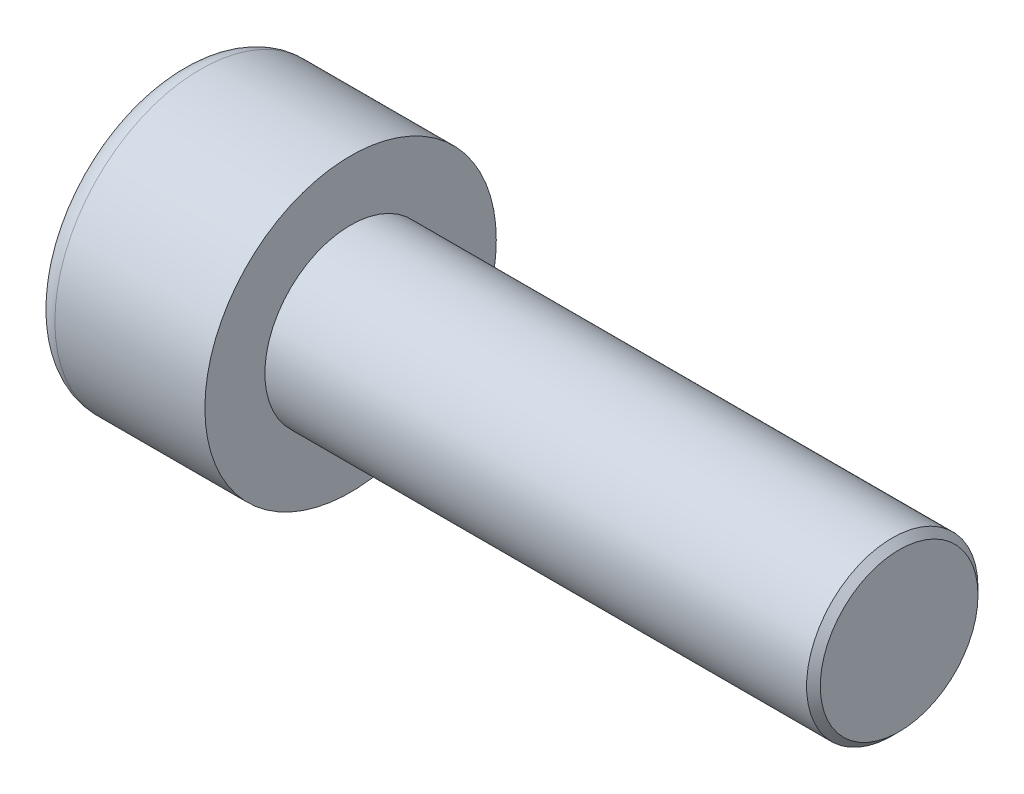
from build123d import *

# Parameters (mm, degrees)
SKETCH1_R           = 4.25
BASEHEAD_DEPTH      = 5
SKETCH2_R           = 2.5
BASEBODY_DEPTH      = 16
HEXAGONSOCKET_DEPTH = 2.5
TOPFILLET_R         = 0.625
CHAMFER1_SIZE       = 0.2


with BuildPart() as part:
    # Sketch1 → BaseHead (new body)
    with BuildSketch(Plane(origin=(0, 0, 0), x_dir=(0, 0, -1), z_dir=(1, 0, 0))):
        Circle(SKETCH1_R)
    extrude(amount=BASEHEAD_DEPTH)

    # Sketch2 → BaseBody (add)
    with BuildSketch(Plane(origin=(5, 0, 0), x_dir=(0, 0, -1), z_dir=(1, 0, 0))):
        Circle(SKETCH2_R)
    extrude(amount=BASEBODY_DEPTH)

    # Sketch3 → HexagonSocket (cut)
    with BuildSketch(Plane(origin=(0, 0, 0), x_dir=(0, 0, -1), z_dir=(1, 0, 0))):
        Polygon((2.309401077, 0), (1.154700538, 2), (-1.154700538, 2), (-2.309401077, 0), (-1.154700538, -2), (1.154700538, -2), align=None)
    extrude(amount=HEXAGONSOCKET_DEPTH, mode=Mode.SUBTRACT)

    # Sketch4 → Cut-Revolve1 (revolve, cut)
    with BuildSketch(Plane(origin=(-4.19613823, 0.75, 0), x_dir=(-1, 0, 0), z_dir=(0, 0, 1))):
        Polygon((-6.69613823, 2.75), (-7.850838768, 0.75), (-6.69613823, 0.75), align=None)
    revolve(axis=Axis((0.838992387, 0, 0), (-1, 0, 0)), mode=Mode.SUBTRACT)

    # TopFillet
    topfillet_edges = [part.edges().sort_by_distance(p)[0] for p in [
        (0, 0, 4.25),
    ]]
    fillet(topfillet_edges, radius=TOPFILLET_R)

    # Chamfer1
    chamfer1_edges = [part.edges().sort_by_distance(p)[0] for p in [
        (21, 0, 2.5),
    ]]
    chamfer(chamfer1_edges, length=CHAMFER1_SIZE)


solid = part.part
